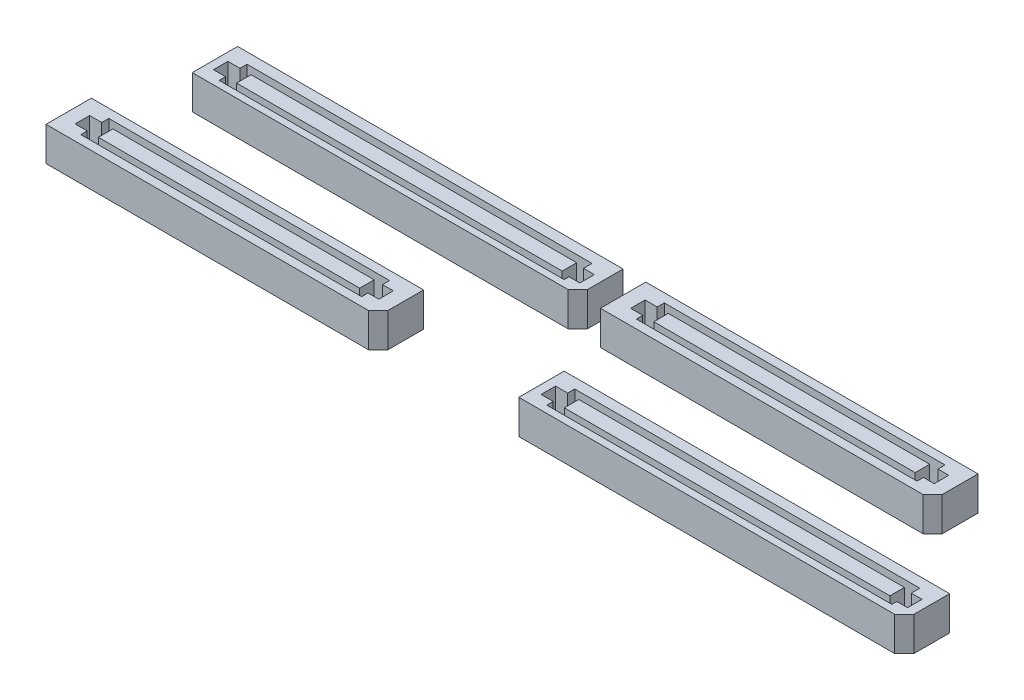
from build123d import *

# Parameters (mm, degrees)
SV_DEPTH           = 3.75
SV_2_DEPTH         = 3.75
SV_3_DEPTH         = 3.75
SV_4_DEPTH         = 3.75
SKETCH3_W          = 28.811718275
SKETCH3_H          = 1.597828601
SKETCH3_W_2        = 35.897762959
SKETCH3_W_3        = 35.897762958
CUT_EXTRUDE1_DEPTH = 3.5


with BuildPart() as part:
    # Sketch1 → SV (new body)
    with BuildSketch(Plane(origin=(0, 0, 0), x_dir=(1, 0, 0), z_dir=(0, 1, 0))):
        Polygon((55.811, 9.5), (97.25, 9.5), (97.25, 5.56), (96.19, 4.5), (54.75, 4.5), (54.75, 8.439), (54.75, 9.5), align=None)
    extrude(amount=SV_DEPTH)


with BuildPart() as body_2:
    # Sketch1 → SV 2 (new body)
    with BuildSketch(Plane(origin=(0, 0, 0), x_dir=(1, 0, 0), z_dir=(0, 1, 0))):
        Polygon((3.686, 9.5), (39.25, 9.5), (39.25, 5.555), (38.195, 4.5), (2.625, 4.5), (2.625, 8.439), (2.625, 9.5), align=None)
    extrude(amount=SV_2_DEPTH)


with BuildPart() as body_3:
    # Sketch1 → SV 3 (new body)
    with BuildSketch(Plane(origin=(0, 0, 0), x_dir=(1, 0, 0), z_dir=(0, 1, 0))):
        Polygon((51.811, 22.5), (87.375, 22.5), (87.375, 18.555), (86.32, 17.5), (50.75, 17.5), (50.75, 21.439), (50.75, 22.5), align=None)
    extrude(amount=SV_3_DEPTH)


with BuildPart() as body_4:
    # Sketch1 → SV 4 (new body)
    with BuildSketch(Plane(origin=(0, 0, 0), x_dir=(1, 0, 0), z_dir=(0, 1, 0))):
        Polygon((6.811, 22.5), (48.25, 22.5), (48.25, 18.56), (47.19, 17.5), (5.75, 17.5), (5.75, 21.439), (5.75, 22.5), align=None)
    extrude(amount=SV_4_DEPTH)


with BuildPart() as cut_extrude1_tool:
    # Sketch3 → Cut-Extrude1 (new body)
    with BuildSketch(Plane(origin=(0, 3.75, 0), x_dir=(1, 0, 0), z_dir=(0, 1, 0))):
        Polygon((4.189336253, 7.745735487), (5.524337048, 7.745735487), (5.524337048, 8.524173538), (36.475691419, 8.524173538), (36.475691419, 7.745735487), (37.666991912, 7.745735487), (37.666991912, 6.147906886), (36.475691419, 6.147906886), (36.475691419, 5.438560322), (5.524337048, 5.438560322), (5.524337048, 6.147906886), (4.189336253, 6.147906886), align=None)
        with Locations((21.152985591, 6.946821187)):
            Rectangle(SKETCH3_W, SKETCH3_H, mode=Mode.SUBTRACT)
        Polygon((52.421116037, 20.753597434), (53.756116831, 20.753597434), (53.756116831, 21.532035485), (84.707471203, 21.532035485), (84.707471203, 20.753597434), (85.898771695, 20.753597434), (85.898771695, 19.155768833), (84.707471203, 19.155768833), (84.707471203, 18.446422269), (53.756116831, 18.446422269), (53.756116831, 19.155768833), (52.421116037, 19.155768833), align=None)
        with Locations((69.384765375, 19.954683133)):
            Rectangle(SKETCH3_W, SKETCH3_H, mode=Mode.SUBTRACT)
        Polygon((55.705906871, 7.599031898), (57.040907666, 7.599031898), (57.040907666, 8.377469948), (95.07830672, 8.377469948), (95.07830672, 7.437727621), (96.269607213, 7.437727621), (96.269607213, 5.83989902), (95.07830672, 5.83989902), (95.07830672, 5.291856733), (57.040907666, 5.291856733), (57.040907666, 6.001203297), (55.705906871, 6.001203297), align=None)
        with Locations((76.21257855, 6.800117597)):
            Rectangle(SKETCH3_W_2, SKETCH3_H, mode=Mode.SUBTRACT)
        Polygon((6.636601859, 20.53972103), (7.971602653, 20.53972103), (7.971602653, 21.318159081), (46.009001708, 21.318159081), (46.009001708, 20.378416754), (47.2003022, 20.378416754), (47.2003022, 18.780588153), (46.009001708, 18.780588153), (46.009001708, 18.232545866), (7.971602653, 18.232545866), (7.971602653, 18.941892429), (6.636601859, 18.941892429), align=None)
        with Locations((27.143273538, 19.74080673)):
            Rectangle(SKETCH3_W_3, SKETCH3_H, mode=Mode.SUBTRACT)
    extrude(amount=-CUT_EXTRUDE1_DEPTH)


with BuildPart() as part_1:
    add(part.part)

    # Cut-Extrude1: cut by cut_extrude1_tool
    add(cut_extrude1_tool.part, mode=Mode.SUBTRACT)


with BuildPart() as body_2_1:
    add(body_2.part)

    # Cut-Extrude1: cut by cut_extrude1_tool
    add(cut_extrude1_tool.part, mode=Mode.SUBTRACT)


with BuildPart() as body_3_1:
    add(body_3.part)

    # Cut-Extrude1: cut by cut_extrude1_tool
    add(cut_extrude1_tool.part, mode=Mode.SUBTRACT)


with BuildPart() as body_4_1:
    add(body_4.part)

    # Cut-Extrude1: cut by cut_extrude1_tool
    add(cut_extrude1_tool.part, mode=Mode.SUBTRACT)


solid = Compound([part_1.part, body_2_1.part, body_3_1.part, body_4_1.part])
